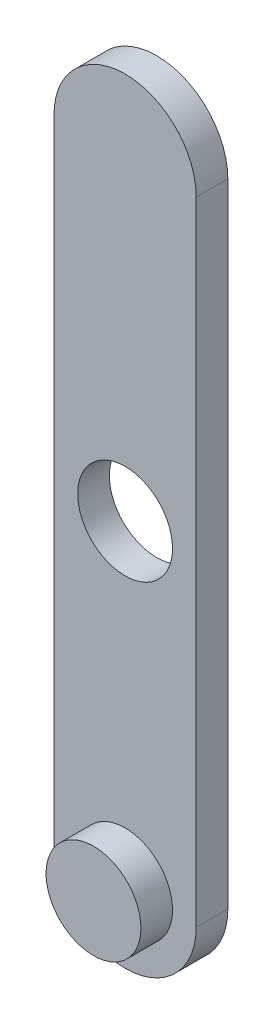
from build123d import *

# Parameters (mm, degrees)
SKETCH_1_R      = 3
EXTRUDE_1_DEPTH = 2
SKETCH_2_R      = 3
EXTRUDE_2_DEPTH = 2


with BuildPart() as part:
    # 草图1 → 凸台-拉伸1 (new body)
    with BuildSketch(Plane.XY):
        with BuildLine():
            Line((-4.5, -20), (-4.5, 20))
            ThreePointArc((-4.5, 20), (0, 24.5), (4.5, 20))
            Line((4.5, 20), (4.5, -20))
            ThreePointArc((4.5, -20), (0, -24.5), (-4.5, -20))
        make_face()
        Circle(SKETCH_1_R, mode=Mode.SUBTRACT)
    extrude(amount=EXTRUDE_1_DEPTH)

    # 草图2 → 凸台-拉伸2 (add)
    with BuildSketch(Plane.XY.offset(2)):
        with Locations((0, -19.804668681)):
            Circle(SKETCH_2_R)
    extrude(amount=EXTRUDE_2_DEPTH)


solid = part.part
